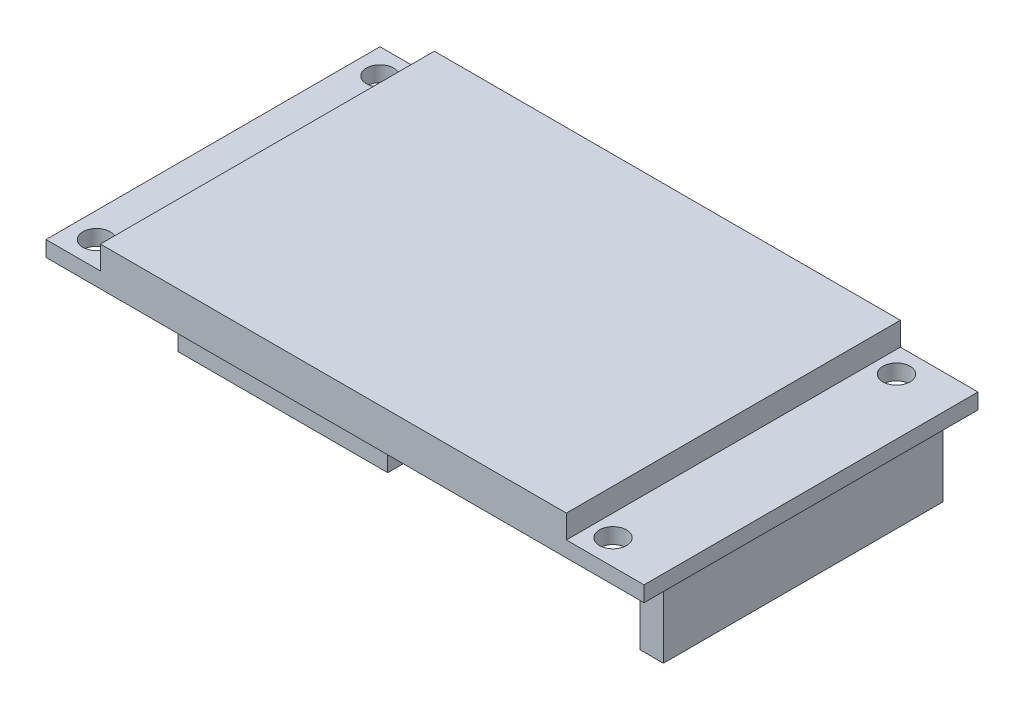
from build123d import *

# Parameters (mm, degrees)
SKETCH1_W           = 60
SKETCH1_H           = 43
BOSS_EXTRUDE1_DEPTH = 5
SKETCH1_3_W         = 7
SKETCH1_3_H         = 43
SKETCH1_3_W_2       = 10
BOSS_EXTRUDE2_DEPTH = 2
SKETCH2_R           = 1.75
CUT_EXTRUDE1_DEPTH  = 2
SKETCH3_R           = 1.75
CUT_EXTRUDE2_DEPTH  = 2
SKETCH4_W           = 3
SKETCH4_H           = 36
BOSS_EXTRUDE3_DEPTH = 9
SKETCH5_W           = 27
SKETCH5_H           = 18
BOSS_EXTRUDE4_DEPTH = 3


with BuildPart() as part:
    # Sketch1 → Boss-Extrude1 (new body)
    with BuildSketch(Plane(origin=(0, 0, 0), x_dir=(1, 0, 0), z_dir=(0, 1, 0))):
        with Locations((-1.5, 0)):
            Rectangle(SKETCH1_W, SKETCH1_H)
    extrude(amount=BOSS_EXTRUDE1_DEPTH)

    # Sketch1_3 → Boss-Extrude2 (add)
    with BuildSketch(Plane(origin=(0, 0, 0), x_dir=(1, 0, 0), z_dir=(0, 1, 0))):
        with Locations((-35, 0)):
            Rectangle(SKETCH1_3_W, SKETCH1_3_H)
        with Locations((33.5, 0)):
            Rectangle(SKETCH1_3_W_2, SKETCH1_3_H)
    extrude(amount=BOSS_EXTRUDE2_DEPTH)

    # Sketch2 → Cut-Extrude1 (cut)
    with BuildSketch(Plane(origin=(0, 2, 0), x_dir=(1, 0, 0), z_dir=(0, 1, 0))):
        with Locations((31.25, 18.25)):
            Circle(SKETCH2_R)
        with Locations((31.25, -18.25)):
            Circle(SKETCH2_R)
    extrude(amount=-CUT_EXTRUDE1_DEPTH, mode=Mode.SUBTRACT)

    # Sketch3 → Cut-Extrude2 (cut)
    with BuildSketch(Plane(origin=(0, 2, 0), x_dir=(1, 0, 0), z_dir=(0, 1, 0))):
        with Locations((-35.25, 18.25)):
            Circle(SKETCH3_R)
        with Locations((-35.25, -18.25)):
            Circle(SKETCH3_R)
    extrude(amount=-CUT_EXTRUDE2_DEPTH, mode=Mode.SUBTRACT)

    # Sketch4 → Boss-Extrude3 (add)
    with BuildSketch(Plane.XZ):
        with Locations((36, 0)):
            Rectangle(SKETCH4_W, SKETCH4_H)
    extrude(amount=BOSS_EXTRUDE3_DEPTH)

    # Sketch5 → Boss-Extrude4 (add)
    with BuildSketch(Plane.XZ):
        with Locations((-9, 11.5)):
            Rectangle(SKETCH5_W, SKETCH5_H)
    extrude(amount=BOSS_EXTRUDE4_DEPTH)


solid = part.part
